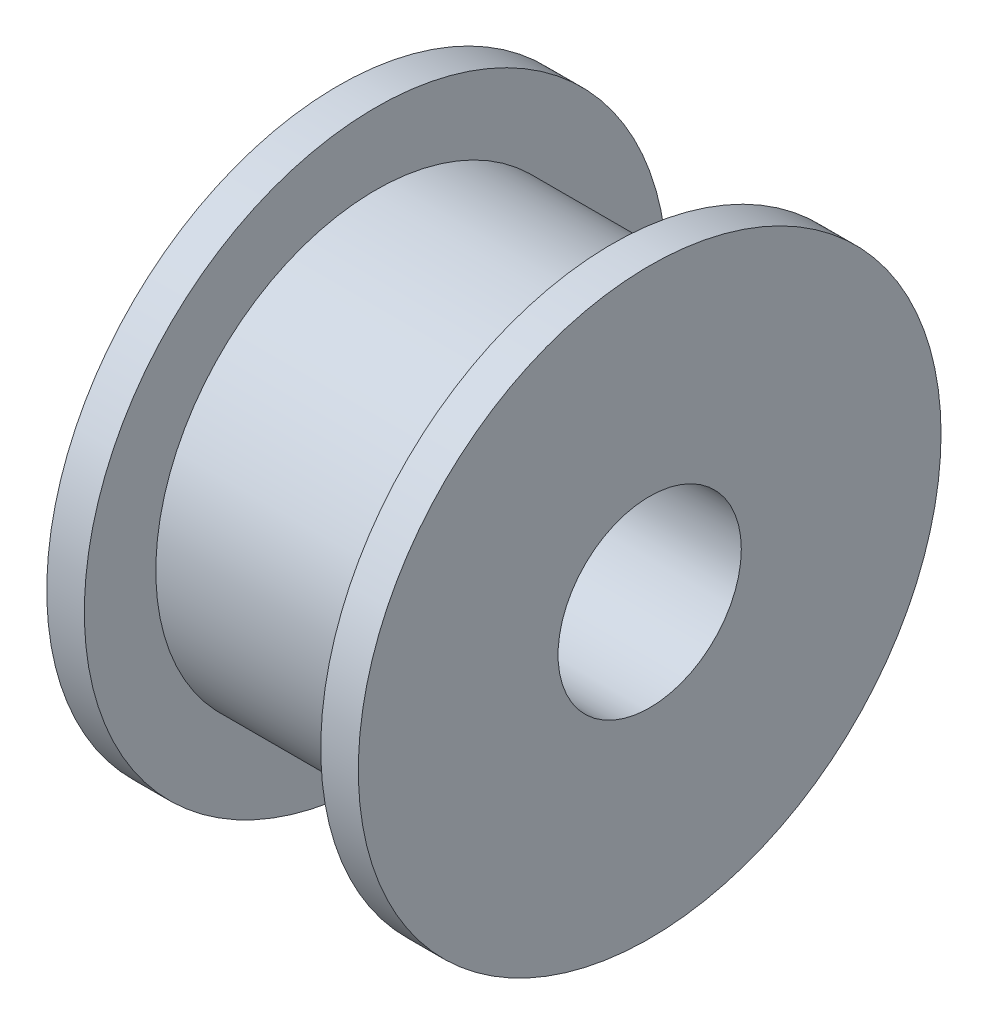
from build123d import *


with BuildPart() as part:
    # Sketch1 → Revolve1 (revolve)
    with BuildSketch(Plane.XY):
        Polygon((8.268847172, 7.95), (8.268847172, 2.5), (16.768847172, 2.5), (16.768847172, 7.95), (15.743847172, 7.95), (15.743847172, 6), (9.293847172, 6), (9.293847172, 7.95), align=None)
    revolve(axis=Axis((0, 0, 0), (-1, 0, 0)))


solid = part.part
